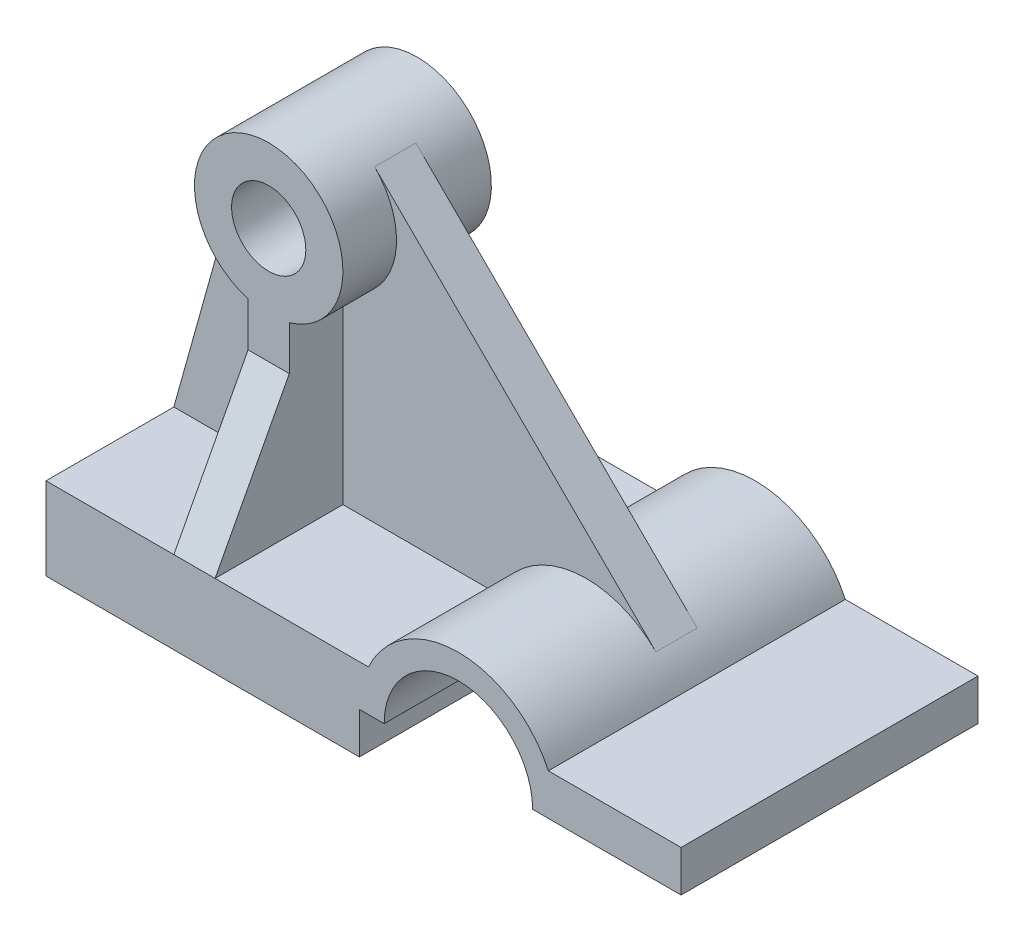
from build123d import *

# Parameters (mm, degrees)
BOSS_EXTRUDE1_DEPTH = 72
SKETCH2_W           = 36
SKETCH2_H           = 36
BOSS_EXTRUDE3_DEPTH = 80
SKETCH4_R           = 9
CUT_EXTRUDE2_DEPTH  = 80
CUT_EXTRUDE3_DEPTH  = 80
RIB1_REACH          = 155.827
SKETCH7_WALL_W      = 405.799744174
SKETCH7_WALL_H      = 10
RIB4_REACH          = 155.827
SKETCH8_WALL_W      = 379.051427732
SKETCH8_WALL_H      = 10
RIB5_REACH          = 171.554
SKETCH12_WALL_W     = 379.578938684
SKETCH12_WALL_H     = 10


with BuildPart() as part:
    # Sketch1 → Boss-Extrude1 (new body)
    with BuildSketch(Plane.XY):
        with BuildLine():
            Line((-41.189710611, -1.813504823), (34.810289389, -1.813504823))
            Line((34.810289389, -1.813504823), (34.810289389, 8.186495177))
            Line((34.810289389, 8.186495177), (40.810289389, 8.186495177))
            ThreePointArc((40.810289389, 8.186495177), (58.810289389, 26.186495177), (76.810289389, 8.186495177))
            Line((76.810289389, 8.186495177), (112.810289389, 8.186495177))
            Line((112.810289389, 8.186495177), (112.810289389, 18.186495177))
            Line((112.810289389, 18.186495177), (80.627713618, 18.186495177))
            ThreePointArc((80.627713618, 18.186495177), (58.810289389, 32.186495177), (36.99286516, 18.186495177))
            Line((36.99286516, 18.186495177), (-41.189710611, 18.186495177))
            Line((-41.189710611, 18.186495177), (-41.189710611, -1.813504823))
        make_face()
    extrude(amount=-BOSS_EXTRUDE1_DEPTH)

    # Sketch2 → Boss-Extrude3 (add)
    with BuildSketch(Plane(origin=(0, 18.186495177, 0), x_dir=(1, 0, 0), z_dir=(0, 1, 0))):
        with Locations((-5.189710611, 36)):
            Rectangle(SKETCH2_W, SKETCH2_H)
    extrude(amount=BOSS_EXTRUDE3_DEPTH)

    # Sketch4 → Cut-Extrude2 (cut)
    with BuildSketch(Plane.XY.offset(-18)):
        with Locations((-5.189710611, 80.186495177)):
            Circle(SKETCH4_R)
    extrude(amount=-CUT_EXTRUDE2_DEPTH, mode=Mode.SUBTRACT)

    # Sketch5 → Cut-Extrude3 (cut)
    with BuildSketch(Plane.XY.offset(-18)):
        with BuildLine():
            Line((-10.189710611, 18.186495177), (-10.189710611, 62.186495177))
            Line((-10.189710611, 62.186495177), (-10.189710611, 62.894878711))
            ThreePointArc((-10.189710611, 62.894878711), (-19.577205181, 69.36984135), (-23.189710611, 80.186495177))
            Line((-23.189710611, 80.186495177), (-23.189710611, 18.186495177))
            Line((-23.189710611, 18.186495177), (-10.189710611, 18.186495177))
        make_face()
        with BuildLine():
            Line((-0.189710611, 62.186495177), (-0.189710611, 18.186495177))
            Line((-0.189710611, 18.186495177), (12.810289389, 18.186495177))
            Line((12.810289389, 18.186495177), (12.810289389, 80.186495177))
            ThreePointArc((12.810289389, 80.186495177), (9.197783959, 69.36984135), (-0.189710611, 62.894878711))
            Line((-0.189710611, 62.894878711), (-0.189710611, 62.186495177))
        make_face()
        with BuildLine():
            Line((12.810289389, 98.186495177), (-5.1897106, 98.186495177))
            ThreePointArc((-5.1897106, 98.186495177), (7.538211454, 92.914417234), (12.810289389, 80.186495177))
            Line((12.810289389, 80.186495177), (12.810289389, 98.186495177))
        make_face()
        with BuildLine():
            Line((-23.189710611, 98.186495177), (-23.189710611, 80.186495177))
            ThreePointArc((-23.189710611, 80.186495177), (-17.917632668, 92.914417242), (-5.1897106, 98.186495177))
            Line((-5.1897106, 98.186495177), (-23.189710611, 98.186495177))
        make_face()
    extrude(amount=-CUT_EXTRUDE3_DEPTH, mode=Mode.SUBTRACT)

    # Sketch7 wall → Rib1 (add, up to next)
    with BuildSketch(Plane(origin=(41.606445938, 59.088634331, -36), x_dir=(0.709625674027, -0.704578883278, 0), z_dir=(0.704578883278, 0.709625674027, 0)), mode=Mode.PRIVATE) as rib1_sk1:
        Rectangle(SKETCH7_WALL_W, SKETCH7_WALL_H)
    rib1_tool1 = extrude(rib1_sk1.sketch, amount=-RIB1_REACH, mode=Mode.PRIVATE) - part.part
    add(rib1_tool1.solids().sort_by_distance((41.606445938, 59.088634331, -36))[0])

    # Sketch8 wall → Rib4 (add, up to next)
    with BuildSketch(Plane(origin=(-31.858144991, 51.606876429, -36), x_dir=(-0.268931250293, -0.963159375501, 0), z_dir=(0.963159375501, -0.268931250293, 0)), mode=Mode.PRIVATE) as rib4_sk1:
        Rectangle(SKETCH8_WALL_W, SKETCH8_WALL_H)
    rib4_tool1 = extrude(rib4_sk1.sketch, amount=RIB4_REACH, mode=Mode.PRIVATE) - part.part
    add(rib4_tool1.solids().sort_by_distance((-31.858144991, 51.606876429, -36))[0])

    # Sketch12 wall → Rib5 (add, up to next)
    with BuildSketch(Plane(origin=(-5.189710611, 35.186495177, -9), x_dir=(0, -0.883787916347, 0.467887720419), z_dir=(0, 0.467887720419, 0.883787916347)), mode=Mode.PRIVATE) as rib5_sk1:
        Rectangle(SKETCH12_WALL_W, SKETCH12_WALL_H)
    rib5_tool1 = extrude(rib5_sk1.sketch, amount=-RIB5_REACH, mode=Mode.PRIVATE) - part.part
    add(rib5_tool1.solids().sort_by_distance((-5.189710611, 35.186495177, -9))[0])


solid = part.part
